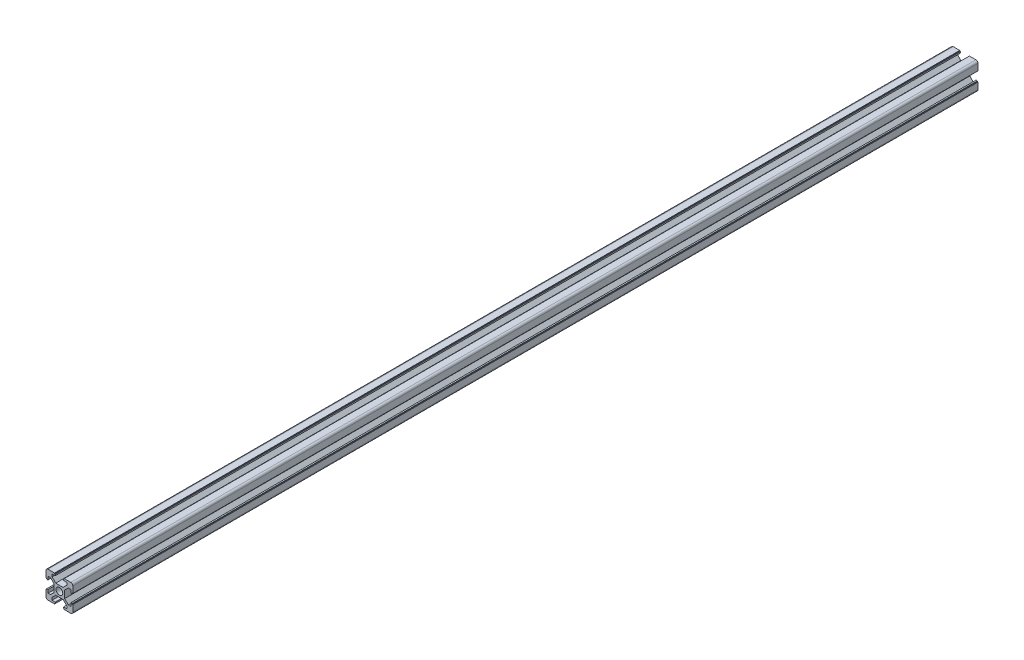
from build123d import *

# Parameters (mm, degrees)
SKETCH_1_R          = 2.5
EXTRUDE_1_DEPTH     = 700
SKETCH_2_W          = 16.527744628
SKETCH_2_H          = 22.497789949
CUT_EXTRUDE_1_DEPTH = 21
SKETCH_3_W          = 8.365047253
SKETCH_3_H          = 23
CUT_EXTRUDE_2_DEPTH = 21


with BuildPart() as part:
    # 草图1 → 凸台-拉伸1 (new body)
    with BuildSketch(Plane.XY):
        with BuildLine():
            Line((-3.6, 10), (-3.6, 9.5))
            Line((-3.6, 9.5), (-3.1, 9.5))
            Line((-3.1, 9.5), (-3.1, 8.5))
            Line((-3.1, 8.5), (-5.5, 8.5))
            Line((-5.5, 8.5), (-5.5, 6.65))
            Line((-5.5, 6.65), (-2.75, 3.9))
            Line((-2.75, 3.9), (2.75, 3.9))
            Line((2.75, 3.9), (5.5, 6.65))
            Line((5.5, 6.65), (5.5, 8.5))
            Line((5.5, 8.5), (3.1, 8.5))
            Line((3.1, 8.5), (3.1, 9.5))
            Line((3.1, 9.5), (3.6, 9.5))
            Line((3.6, 9.5), (3.6, 10))
            Line((3.6, 10), (8.5, 10))
            ThreePointArc((8.5, 10), (9.560660172, 9.560660172), (10, 8.5))
            Line((10, 8.5), (10, 3.6))
            Line((10, 3.6), (9.5, 3.6))
            Line((9.5, 3.6), (9.5, 3.1))
            Line((9.5, 3.1), (8.5, 3.1))
            Line((8.5, 3.1), (8.5, 5.5))
            Line((8.5, 5.5), (6.65, 5.5))
            Line((6.65, 5.5), (3.9, 2.75))
            Line((3.9, 2.75), (3.9, -2.75))
            Line((3.9, -2.75), (6.65, -5.5))
            Line((6.65, -5.5), (8.5, -5.5))
            Line((8.5, -5.5), (8.5, -3.1))
            Line((8.5, -3.1), (9.5, -3.1))
            Line((9.5, -3.1), (9.5, -3.6))
            Line((9.5, -3.6), (10, -3.6))
            Line((10, -3.6), (10, -8.5))
            ThreePointArc((10, -8.5), (9.560660172, -9.560660172), (8.5, -10))
            Line((8.5, -10), (3.6, -10))
            Line((3.6, -10), (3.6, -9.5))
            Line((3.6, -9.5), (3.1, -9.5))
            Line((3.1, -9.5), (3.1, -8.5))
            Line((3.1, -8.5), (5.5, -8.5))
            Line((5.5, -8.5), (5.5, -6.65))
            Line((5.5, -6.65), (2.75, -3.9))
            Line((2.75, -3.9), (-2.75, -3.9))
            Line((-2.75, -3.9), (-5.5, -6.65))
            Line((-5.5, -6.65), (-5.5, -8.5))
            Line((-5.5, -8.5), (-3.1, -8.5))
            Line((-3.1, -8.5), (-3.1, -9.5))
            Line((-3.1, -9.5), (-3.6, -9.5))
            Line((-3.6, -9.5), (-3.6, -10))
            Line((-3.6, -10), (-8.5, -10))
            ThreePointArc((-8.5, -10), (-9.560660172, -9.560660172), (-10, -8.5))
            Line((-10, -8.5), (-10, -3.6))
            Line((-10, -3.6), (-9.5, -3.6))
            Line((-9.5, -3.6), (-9.5, -3.1))
            Line((-9.5, -3.1), (-8.5, -3.1))
            Line((-8.5, -3.1), (-8.5, -5.5))
            Line((-8.5, -5.5), (-6.65, -5.5))
            Line((-6.65, -5.5), (-3.9, -2.75))
            Line((-3.9, -2.75), (-3.9, 2.75))
            Line((-3.9, 2.75), (-6.65, 5.5))
            Line((-6.65, 5.5), (-8.5, 5.5))
            Line((-8.5, 5.5), (-8.5, 3.1))
            Line((-8.5, 3.1), (-9.5, 3.1))
            Line((-9.5, 3.1), (-9.5, 3.6))
            Line((-9.5, 3.6), (-10, 3.6))
            Line((-10, 3.6), (-10, 8.5))
            ThreePointArc((-10, 8.5), (-9.560660172, 9.560660172), (-8.5, 10))
            Line((-8.5, 10), (-3.6, 10))
        make_face()
        Circle(SKETCH_1_R, mode=Mode.SUBTRACT)
    extrude(amount=EXTRUDE_1_DEPTH)

    # 草图2 → 切除-拉伸1 (cut, through all)
    with BuildSketch(Plane.ZY.offset(10)):
        with Locations((691.736127686, -0.569757727)):
            Rectangle(SKETCH_2_W, SKETCH_2_H)
    extrude(amount=-CUT_EXTRUDE_1_DEPTH, mode=Mode.SUBTRACT)

    # 草图3 → 切除-拉伸2 (cut, through all)
    with BuildSketch(Plane.ZY.offset(10)):
        with Locations((4.182523627, 0.497203085)):
            Rectangle(SKETCH_3_W, SKETCH_3_H)
    extrude(amount=-CUT_EXTRUDE_2_DEPTH, mode=Mode.SUBTRACT)


solid = part.part
